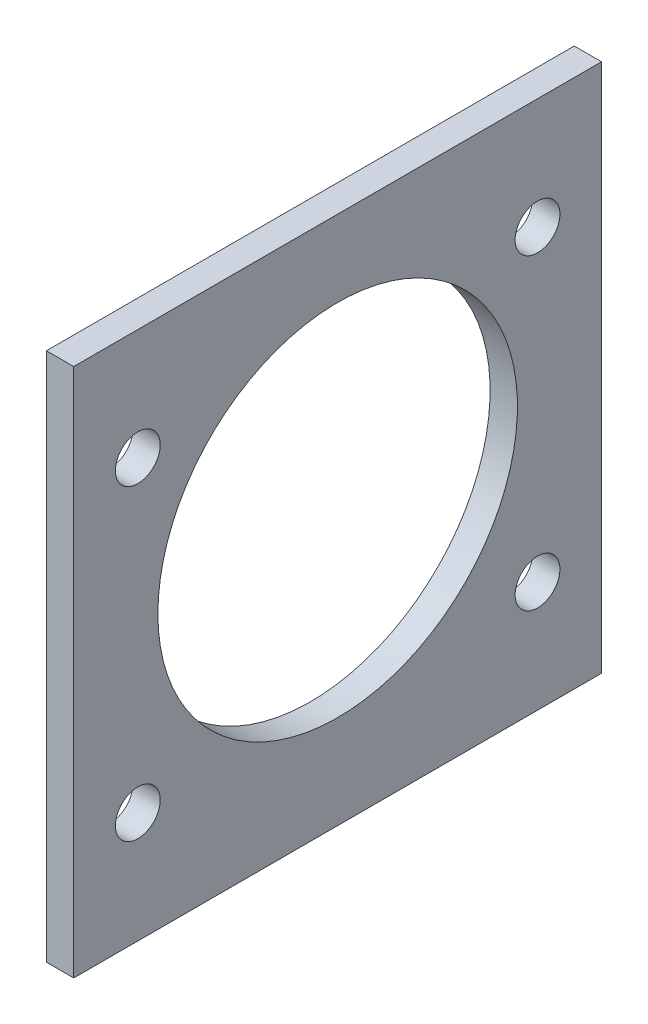
from build123d import *

# Parameters (mm, degrees)
SKETCH1_W           = 61.8
SKETCH1_H           = 62
BOSS_EXTRUDE1_DEPTH = 3.2
CUT_EXTRUDE1_REACH  = 5.2
SKETCH2_R           = 21.05
CUT_EXTRUDE2_REACH  = 5.2
SKETCH3_R           = 2.625


with BuildPart() as part:
    # Sketch1 → Boss-Extrude1 (new body)
    with BuildSketch(Plane(origin=(0, 0, 0), x_dir=(0, 0, -1), z_dir=(1, 0, 0))):
        with Locations((30.9, 31)):
            Rectangle(SKETCH1_W, SKETCH1_H)
    extrude(amount=BOSS_EXTRUDE1_DEPTH)

    # Sketch2 → Cut-Extrude1 (cut, up to next)
    with BuildSketch(Plane(origin=(3.2, 0, 0), x_dir=(0, 0, -1), z_dir=(1, 0, 0)), mode=Mode.PRIVATE) as cut_extrude1_sk1:
        with Locations((30.9, 32)):
            Circle(SKETCH2_R)
    cut_extrude1_tool1 = extrude(cut_extrude1_sk1.sketch, amount=-CUT_EXTRUDE1_REACH, mode=Mode.PRIVATE) & part.part
    add(cut_extrude1_tool1.solids().sort_by_distance((3.2, 32, -30.9))[0], mode=Mode.SUBTRACT)

    # Sketch3 → Cut-Extrude2 (cut, up to next)
    with BuildSketch(Plane.ZY, mode=Mode.PRIVATE) as cut_extrude2_sk1:
        with Locations((-54.3, 49)):
            Circle(SKETCH3_R)
    cut_extrude2_tool1 = extrude(cut_extrude2_sk1.sketch, amount=-CUT_EXTRUDE2_REACH, mode=Mode.PRIVATE) & part.part
    add(cut_extrude2_tool1.solids().sort_by_distance((0, 49, -54.3))[0], mode=Mode.SUBTRACT)
    # Sketch3 → Cut-Extrude2 (cut, up to next)
    with BuildSketch(Plane.ZY, mode=Mode.PRIVATE) as cut_extrude2_sk2:
        with Locations((-54.3, 13)):
            Circle(SKETCH3_R)
    cut_extrude2_tool2 = extrude(cut_extrude2_sk2.sketch, amount=-CUT_EXTRUDE2_REACH, mode=Mode.PRIVATE) & part.part
    add(cut_extrude2_tool2.solids().sort_by_distance((0, 13, -54.3))[0], mode=Mode.SUBTRACT)
    # Sketch3 → Cut-Extrude2 (cut, up to next)
    with BuildSketch(Plane.ZY, mode=Mode.PRIVATE) as cut_extrude2_sk3:
        with Locations((-7.5, 49)):
            Circle(SKETCH3_R)
    cut_extrude2_tool3 = extrude(cut_extrude2_sk3.sketch, amount=-CUT_EXTRUDE2_REACH, mode=Mode.PRIVATE) & part.part
    add(cut_extrude2_tool3.solids().sort_by_distance((0, 49, -7.5))[0], mode=Mode.SUBTRACT)
    # Sketch3 → Cut-Extrude2 (cut, up to next)
    with BuildSketch(Plane.ZY, mode=Mode.PRIVATE) as cut_extrude2_sk4:
        with Locations((-7.5, 13)):
            Circle(SKETCH3_R)
    cut_extrude2_tool4 = extrude(cut_extrude2_sk4.sketch, amount=-CUT_EXTRUDE2_REACH, mode=Mode.PRIVATE) & part.part
    add(cut_extrude2_tool4.solids().sort_by_distance((0, 13, -7.5))[0], mode=Mode.SUBTRACT)


solid = part.part
